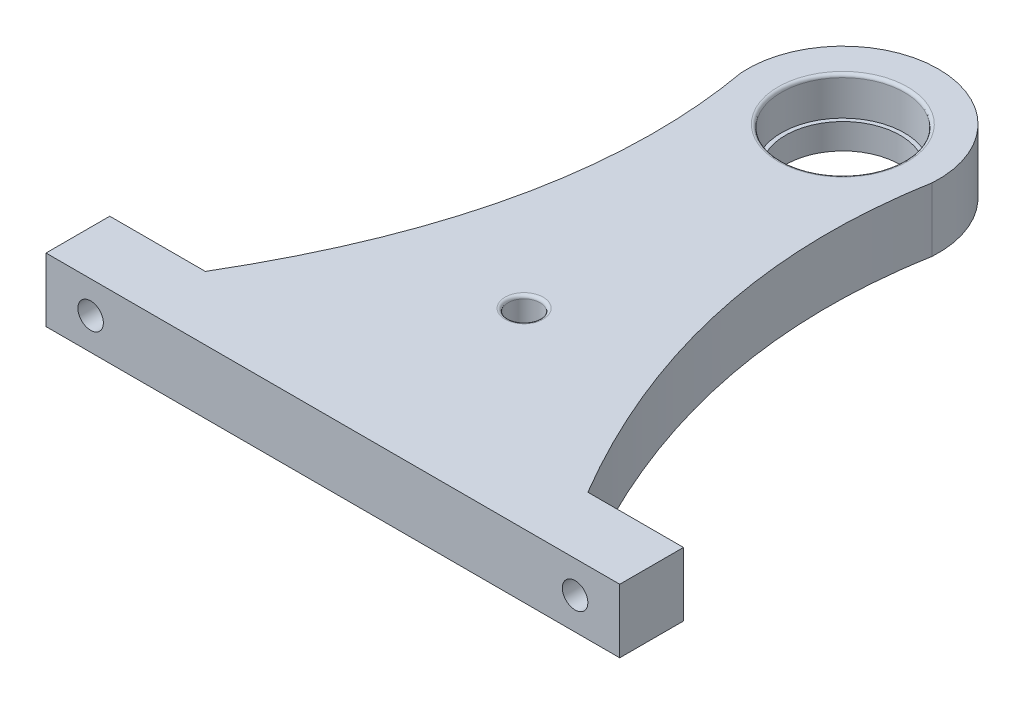
from build123d import *

# Parameters (mm, degrees)
EXTRUDE_1_DEPTH     = 10
SKETCH_2_R          = 9.65
CUT_EXTRUDE_1_DEPTH = 6
SKETCH_3_R          = 9
CUT_EXTRUDE_2_DEPTH = 5.0000001
SKETCH_4_R          = 2
CUT_EXTRUDE_3_DEPTH = 11.0000001
SKETCH_5_R          = 2.5
CUT_EXTRUDE_4_DEPTH = 8
FILLET_1_R          = 0.5
FILLET_2_R          = 0.5


with BuildPart() as part:
    # Эскиз1 → Бобышка-Вытянуть1 (new body)
    with BuildSketch(Plane(origin=(0, 0, 0), x_dir=(1, 0, 0), z_dir=(0, 1, 0))):
        with BuildLine():
            Line((-45, -37.036390428), (45, -37.036390428))
            Line((45, -37.036390428), (45, -27.036390428))
            Line((45, -27.036390428), (30, -27.036390428))
            add(Edge.make_bspline(
                [(30, -27.036390428), (8.982189831, 8.482679734), (14.96841635, 41.990721102)],
                knots=[0, 0, 0, 0.673052388, 0.673052388, 0.673052388], degree=2))
            ThreePointArc((14.96841635, 41.990721102), (0, 57.963609572), (-14.96841635, 41.990721102))
            add(Edge.make_bspline(
                [(-30, -27.036390428), (-8.982189831, 8.482679734), (-14.96841635, 41.990721102)],
                knots=[0, 0, 0, 0.673052388, 0.673052388, 0.673052388], degree=2))
            Line((-30, -27.036390428), (-45, -27.036390428))
            Line((-45, -27.036390428), (-45, -37.036390428))
        make_face()
    extrude(amount=EXTRUDE_1_DEPTH)

    # Эскиз2 → Вырез-Вытянуть1 (cut)
    with BuildSketch(Plane(origin=(0, 10, 0), x_dir=(1, 0, 0), z_dir=(0, 1, 0))):
        with Locations((0, 42.963609572)):
            Circle(SKETCH_2_R)
    extrude(amount=-CUT_EXTRUDE_1_DEPTH, mode=Mode.SUBTRACT)

    # Эскиз3 → Вырез-Вытянуть2 (cut, through all)
    with BuildSketch(Plane(origin=(0, 4, 0), x_dir=(1, 0, 0), z_dir=(0, 1, 0))):
        with Locations((0, 42.963609572)):
            Circle(SKETCH_3_R)
    extrude(amount=-CUT_EXTRUDE_2_DEPTH, mode=Mode.SUBTRACT)

    # Эскиз4 → Вырез-Вытянуть3 (cut, through all)
    with BuildSketch(Plane(origin=(0, 0, 27.036390428), x_dir=(-1, 0, 0), z_dir=(0, 0, -1))):
        with Locations((38, 5)):
            Circle(SKETCH_4_R)
        with Locations((-38, 5)):
            Circle(SKETCH_4_R)
    extrude(amount=-CUT_EXTRUDE_3_DEPTH, mode=Mode.SUBTRACT)

    # Эскиз5 → Вырез-Вытянуть4 (cut)
    with BuildSketch(Plane(origin=(0, 10, 0), x_dir=(1, 0, 0), z_dir=(0, 1, 0))):
        with Locations((0, -7.036390428)):
            Circle(SKETCH_5_R)
    extrude(amount=-CUT_EXTRUDE_4_DEPTH, mode=Mode.SUBTRACT)

    # Скругление1
    fillet_1_edges = [part.edges().sort_by_distance(p)[0] for p in [
        (-2.5, 10, 7.036390428),
    ]]
    fillet(fillet_1_edges, radius=FILLET_1_R)

    # Скругление2
    fillet_2_edges = [part.edges().sort_by_distance(p)[0] for p in [
        (-9.65, 10, -42.963609572),
    ]]
    fillet(fillet_2_edges, radius=FILLET_2_R)


solid = part.part
